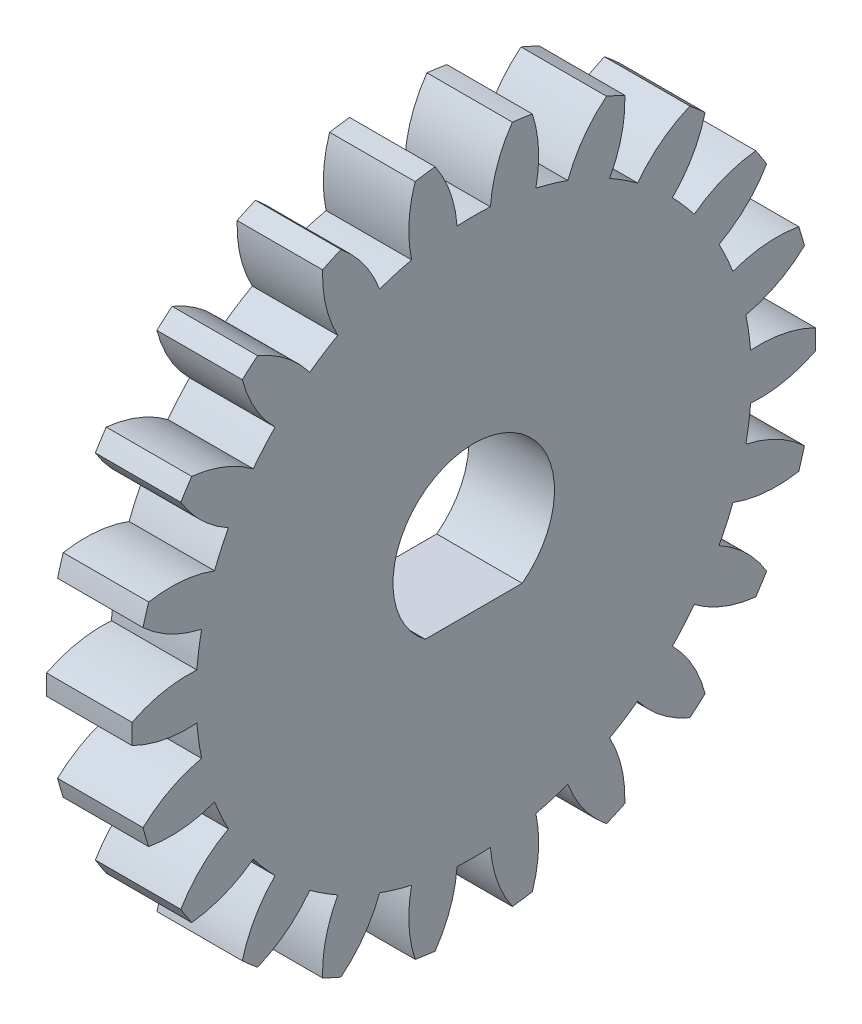
from build123d import *

# Parameters (mm, degrees)
BASPROSKE_W        = 3.175
BASPROSKE_H        = 12.7
TOOTHCUT_DEPTH     = 19.238986403
TEETHCUTS_COUNT    = 22
TEETHCUTS_ANGLE    = 343.636363636
CUT_EXTRUDE1_REACH = 20.182


with BuildPart() as part:
    # BasProSke → Base-Revolve (revolve)
    with BuildSketch(Plane(origin=(0, 0, 0), x_dir=(1, 0, 0), z_dir=(0, 1, 0)), mode=Mode.PRIVATE) as base_revolve_sk:
        with Locations((1.5875, 6.35)):
            Rectangle(BASPROSKE_W, BASPROSKE_H)
    revolve(base_revolve_sk.sketch.rotate(Axis((-10, 0, 0), (1, 0, 0)), 180), axis=Axis((-10, 0, 0), (1, 0, 0)))

    # TooCutSke → ToothCut (cut, through all)
    with BuildSketch(Plane(origin=(0, 0, 0), x_dir=(0, 0, -1), z_dir=(1, 0, 0))):
        with BuildLine():
            ThreePointArc((0.618908626, 10.302292991), (0, 10.320866667), (-0.618908626, 10.302292991))
            ThreePointArc((-0.618908626, 10.302292991), (-0.876745986, 11.528868728), (-1.452383887, 12.64224609))
            ThreePointArc((-1.452383887, 12.64224609), (0, 12.7254), (1.452383887, 12.64224609))
            ThreePointArc((1.452383887, 12.64224609), (0.876745986, 11.528868728), (0.618908626, 10.302292991))
        make_face()
    toothcut = extrude(amount=TOOTHCUT_DEPTH, mode=Mode.SUBTRACT)

    # TeethCuts: ToothCut ×22 about axis
    teethcuts_axis = Axis((-10, 0, 0), (1, 0, 0))
    for i in range(1, TEETHCUTS_COUNT):
        add(toothcut.rotate(teethcuts_axis, i * TEETHCUTS_ANGLE / (TEETHCUTS_COUNT - 1)), mode=Mode.SUBTRACT)

    # Sketch1 → Cut-Extrude1 (cut, up to next)
    with BuildSketch(Plane(origin=(3.175, 0, 0), x_dir=(0, 0, -1), z_dir=(1, 0, 0)), mode=Mode.PRIVATE) as cut_extrude1_sk1:
        with BuildLine():
            Line((-1.8, -2.4), (1.8, -2.4))
            ThreePointArc((1.8, -2.4), (0, 3), (-1.8, -2.4))
        make_face()
    cut_extrude1_tool1 = extrude(cut_extrude1_sk1.sketch, amount=-CUT_EXTRUDE1_REACH, mode=Mode.PRIVATE) & part.part
    add(cut_extrude1_tool1.solids().sort_by_distance((3.175, 0.145059, 0))[0], mode=Mode.SUBTRACT)


solid = part.part
